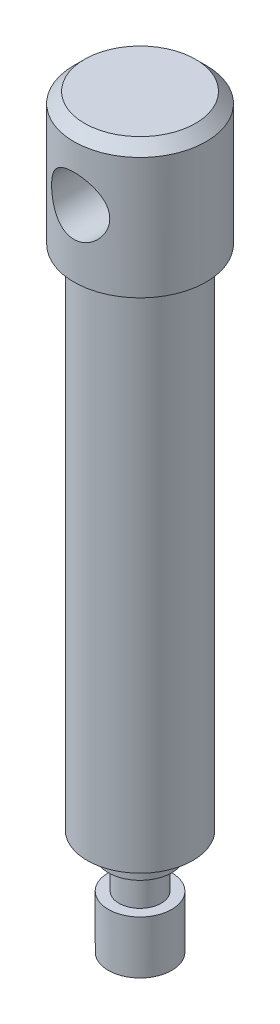
from build123d import *

# Parameters (mm, degrees)
SKETCH2_R               = 5.5
CUT_EXTRUDE1_DEPTH      = 13.5
CUT_EXTRUDE1_DEPTH_BACK = 13.5
CHAMFER1_SIZE           = 2


with BuildPart() as part:
    # Sketch1 → Revolve1 (revolve)
    with BuildSketch(Plane.XY, mode=Mode.PRIVATE) as revolve1_sk:
        Polygon((0, 0), (6, 3.464101615), (6, 13.464101615), (4, 13.464101615), (4, 19.464101615), (6, 19.464101615), (6, 23.464101615), (10, 23.464101615), (10, 119.464101615), (12.5, 119.464101615), (12.5, 144.464101615), (0, 144.464101615), align=None)
    revolve(revolve1_sk.sketch.rotate(Axis((0, 0, 0), (0, 1, 0)), 90), axis=Axis((0, 0, 0), (0, 1, 0)))  # turned: the seam where the file's is

    # Sketch2 → Cut-Extrude1 (cut, two sides)
    with BuildSketch(Plane.XY) as cut_extrude1_sk:
        with Locations((0, 131.964101615)):
            Circle(SKETCH2_R)
    extrude(amount=CUT_EXTRUDE1_DEPTH, mode=Mode.SUBTRACT)
    extrude(cut_extrude1_sk.sketch, amount=-CUT_EXTRUDE1_DEPTH_BACK, mode=Mode.SUBTRACT)

    # Chamfer1
    chamfer1_edges = [part.edges().sort_by_distance(p)[0] for p in [
        (0, 144.464101615, 12.5),
    ]]
    chamfer(chamfer1_edges, length=CHAMFER1_SIZE)


solid = part.part
